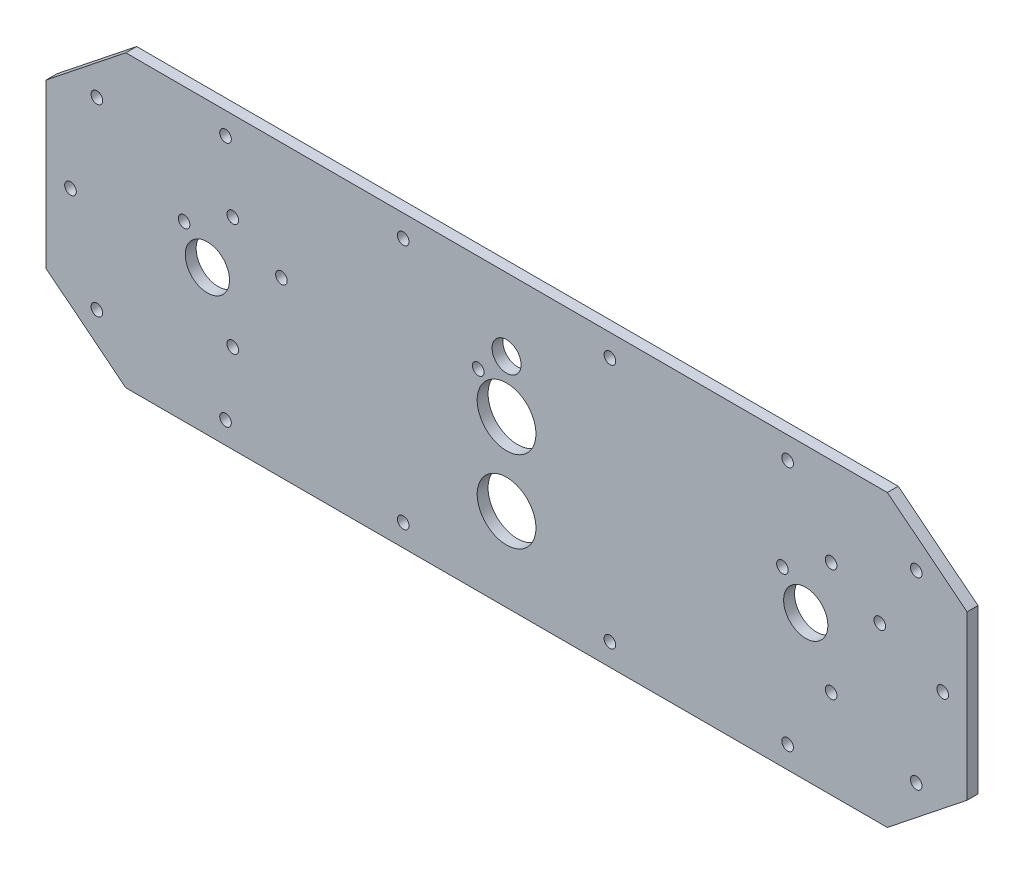
from build123d import *

# Parameters (mm, degrees)
CROQUIS1_R              = 4
CROQUIS1_R_2            = 1.6
CROQUIS1_R_3            = 6.1
CROQUIS1_R_4            = 8.1
SALIENTE_EXTRUIR1_DEPTH = 3


with BuildPart() as part:
    # Croquis1 → Saliente-Extruir1 (new body)
    with BuildSketch(Plane.XY):
        Polygon((-127, 22.5), (-105, 40), (105, 40), (127, 22.5), (127, -22.5), (105, -40), (-105, -40), (-127, -22.5), align=None)
        with Locations((0, 20)):
            Circle(CROQUIS1_R, mode=Mode.SUBTRACT)
        with Locations((112.98, 25.35)):
            Circle(CROQUIS1_R_2, mode=Mode.SUBTRACT)
        with Locations((120.25, 0)):
            Circle(CROQUIS1_R_2, mode=Mode.SUBTRACT)
        with Locations((112.98, -25.35)):
            Circle(CROQUIS1_R_2, mode=Mode.SUBTRACT)
        with Locations((77.5, -33.9)):
            Circle(CROQUIS1_R_2, mode=Mode.SUBTRACT)
        with Locations((28.5, -33.9)):
            Circle(CROQUIS1_R_2, mode=Mode.SUBTRACT)
        with Locations((-28.5, -33.9)):
            Circle(CROQUIS1_R_2, mode=Mode.SUBTRACT)
        with Locations((-77.5, -33.9)):
            Circle(CROQUIS1_R_2, mode=Mode.SUBTRACT)
        with Locations((-112.98, -25.35)):
            Circle(CROQUIS1_R_2, mode=Mode.SUBTRACT)
        with Locations((-120.25, 0)):
            Circle(CROQUIS1_R_2, mode=Mode.SUBTRACT)
        with Locations((-112.98, 25.35)):
            Circle(CROQUIS1_R_2, mode=Mode.SUBTRACT)
        with Locations((-77.5, 33.9)):
            Circle(CROQUIS1_R_2, mode=Mode.SUBTRACT)
        with Locations((-28.5, 33.9)):
            Circle(CROQUIS1_R_2, mode=Mode.SUBTRACT)
        with Locations((28.5, 33.9)):
            Circle(CROQUIS1_R_2, mode=Mode.SUBTRACT)
        with Locations((77.5, 33.9)):
            Circle(CROQUIS1_R_2, mode=Mode.SUBTRACT)
        with Locations((-82.5, 0)):
            Circle(CROQUIS1_R_3, mode=Mode.SUBTRACT)
        with Locations((82.5, 0)):
            Circle(CROQUIS1_R_3, mode=Mode.SUBTRACT)
        with Locations((0, 5.55)):
            Circle(CROQUIS1_R_4, mode=Mode.SUBTRACT)
        with Locations((0, -16.95)):
            Circle(CROQUIS1_R_4, mode=Mode.SUBTRACT)
        with Locations((-7.8, 13.1)):
            Circle(CROQUIS1_R_2, mode=Mode.SUBTRACT)
        with Locations((-88.923393759, 7.75)):
            Circle(CROQUIS1_R_2, mode=Mode.SUBTRACT)
        with Locations((-62.076606241, 7.75)):
            Circle(CROQUIS1_R_2, mode=Mode.SUBTRACT)
        with Locations((-75.5, 15.5)):
            Circle(CROQUIS1_R_2, mode=Mode.SUBTRACT)
        with Locations((-75.5, -15.5)):
            Circle(CROQUIS1_R_2, mode=Mode.SUBTRACT)
        with Locations((89.5, 15.5)):
            Circle(CROQUIS1_R_2, mode=Mode.SUBTRACT)
        with Locations((89.5, -15.5)):
            Circle(CROQUIS1_R_2, mode=Mode.SUBTRACT)
        with Locations((76.076606241, 7.75)):
            Circle(CROQUIS1_R_2, mode=Mode.SUBTRACT)
        with Locations((102.923393759, 7.75)):
            Circle(CROQUIS1_R_2, mode=Mode.SUBTRACT)
    extrude(amount=SALIENTE_EXTRUIR1_DEPTH)


solid = part.part
